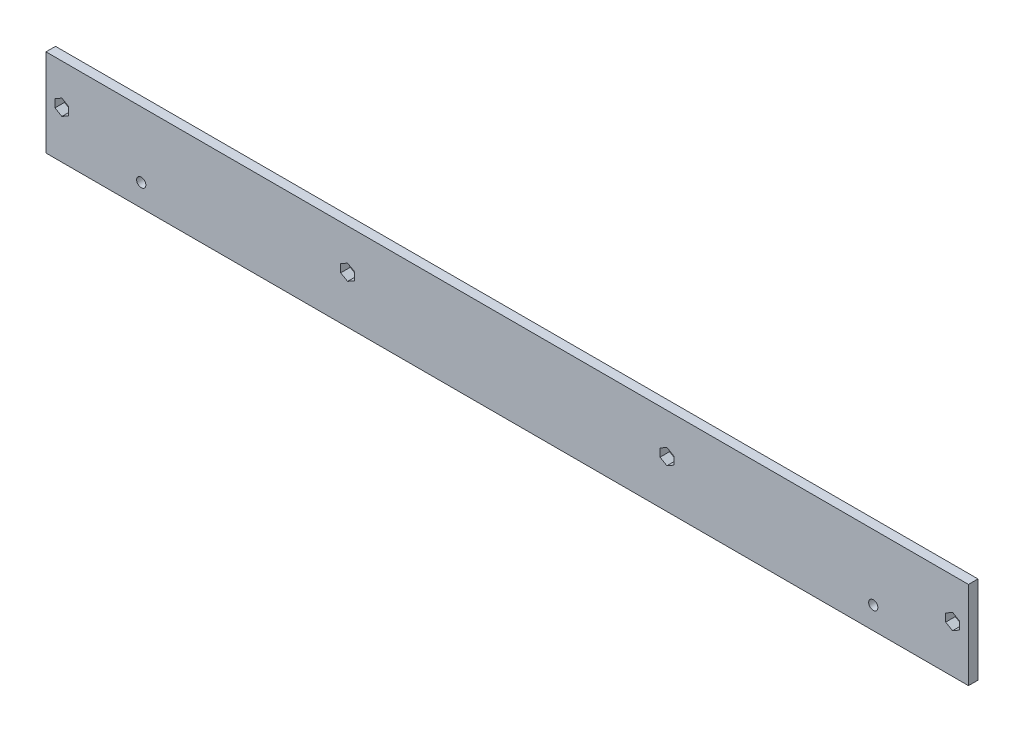
from build123d import *

# Parameters (mm, degrees)
ESQUISSE5_W             = 290.597320494
ESQUISSE5_H             = 27.625
ESQUISSE5_R             = 1.1
EXTRUSION1_DEPTH        = 3
ESQUISSE4_R             = 1.45
ENL_V_MAT_EXTRU_2_DEPTH = 4
ENL_V_MAT_EXTRU_3_DEPTH = 4


with BuildPart() as part:
    # Esquisse5 → Extrusion1 (new body)
    with BuildSketch(Plane.XY):
        with Locations((141.37166943, 13.8125)):
            Rectangle(ESQUISSE5_W, ESQUISSE5_H)
        with Locations((281.670329677, 15)):
            Circle(ESQUISSE5_R, mode=Mode.SUBTRACT)
        with Locations((91.073009183, 15)):
            Circle(ESQUISSE5_R, mode=Mode.SUBTRACT)
        with Locations((1.073009183, 15)):
            Circle(ESQUISSE5_R, mode=Mode.SUBTRACT)
        with Locations((191.670329678, 15)):
            Circle(ESQUISSE5_R, mode=Mode.SUBTRACT)
    extrude(amount=EXTRUSION1_DEPTH)

    # Esquisse4 → Enlèv. mat.-Extru.2 (cut, through all)
    with BuildSketch(Plane.XY.offset(3)):
        with Locations((26.073009183, 7)):
            Circle(ESQUISSE4_R)
        with Locations((256.670329678, 7)):
            Circle(ESQUISSE4_R)
    extrude(amount=-ENL_V_MAT_EXTRU_2_DEPTH, mode=Mode.SUBTRACT)

    # Esquisse6 → Enlèv. mat.-Extru.3 (cut, through all)
    with BuildSketch(Plane(origin=(0, 0, 0), x_dir=(-1, 0, 0), z_dir=(0, 0, -1))):
        Polygon((-1.073009183, 12.5), (1.092054327, 13.75), (1.092054327, 16.25), (-1.073009183, 17.5), (-3.238072692, 16.25), (-3.238072692, 13.75), align=None)
        Polygon((-88.907945673, 13.75), (-88.907945673, 16.25), (-91.073009183, 17.5), (-93.238072692, 16.25), (-93.238072692, 13.75), (-91.073009183, 12.5), align=None)
        Polygon((-189.505266168, 13.75), (-189.505266168, 16.25), (-191.670329677, 17.5), (-193.835393187, 16.25), (-193.835393187, 13.75), (-191.670329677, 12.5), align=None)
        Polygon((-279.505266168, 13.75), (-279.505266168, 16.25), (-281.670329678, 17.5), (-283.835393187, 16.25), (-283.835393187, 13.75), (-281.670329677, 12.5), align=None)
    extrude(amount=-ENL_V_MAT_EXTRU_3_DEPTH, mode=Mode.SUBTRACT)


solid = part.part
